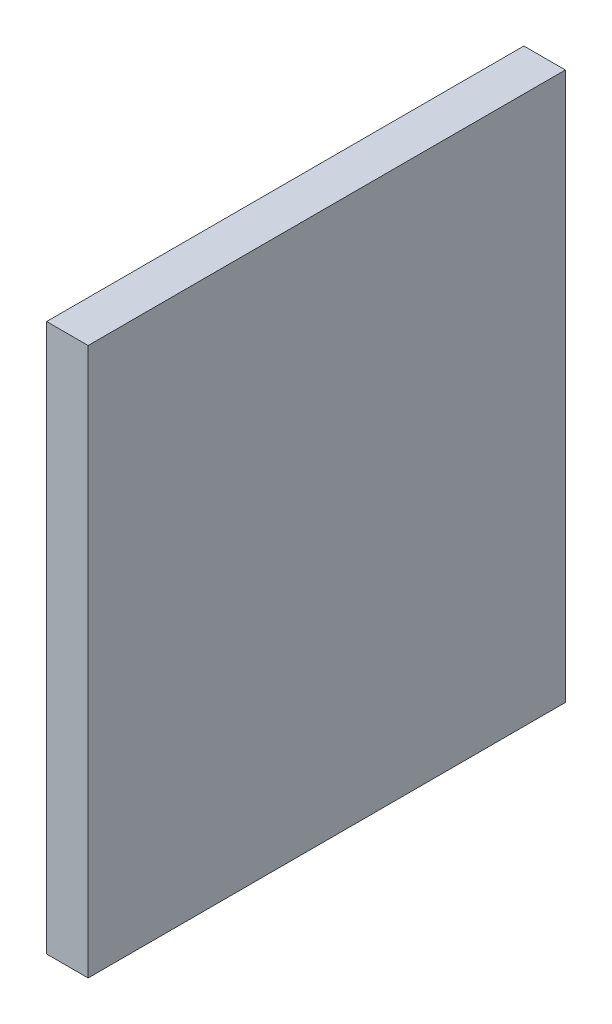
from build123d import *

# Parameters (mm, degrees)
SKETCH1_W           = 36.5125
SKETCH1_H           = 41.91
BOSS_EXTRUDE1_DEPTH = 3.175


with BuildPart() as part:
    # Sketch1 → Boss-Extrude1 (new body)
    with BuildSketch(Plane(origin=(0, 0, 0), x_dir=(0, 0, -1), z_dir=(1, 0, 0))):
        Rectangle(SKETCH1_W, SKETCH1_H)
    extrude(amount=BOSS_EXTRUDE1_DEPTH)


solid = part.part
